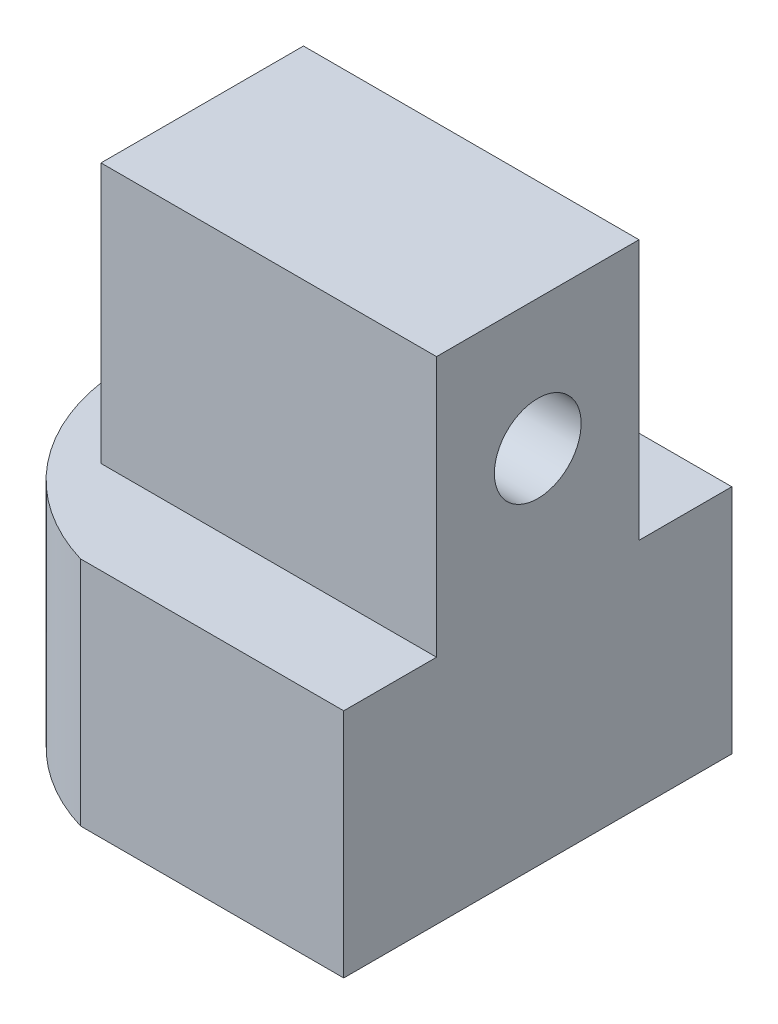
from build123d import *

# Parameters (mm, degrees)
SKETCH1_R           = 7
SKETCH1_R_2         = 4
BOSS_EXTRUDE1_DEPTH = 6
SKETCH2_R           = 7
BOSS_EXTRUDE2_DEPTH = 10
CUT_EXTRUDE1_DEPTH  = 8
SKETCH4_W           = 4.3
SKETCH4_H           = 6.3
CUT_EXTRUDE2_DEPTH  = 6
SKETCH5_OUTSIDE_W   = 21.092
SKETCH5_OUTSIDE_H   = 21.092
CUT_EXTRUDE3_DEPTH  = 8
BOSS_EXTRUDE3_DEPTH = 8
SKETCH9_R           = 7
CUT_EXTRUDE6_DEPTH  = 8
SKETCH10_W          = 9
SKETCH10_H          = 7
BOSS_EXTRUDE5_DEPTH = 9
SKETCH11_W          = 4.3
SKETCH11_H          = 6.3
CUT_EXTRUDE7_DEPTH  = 6
BOSS_EXTRUDE6_DEPTH = 8
SKETCH14_W          = 7
SKETCH14_H          = 9
BOSS_EXTRUDE7_DEPTH = 2.6
SKETCH15_W          = 4
SKETCH15_H          = 5
CUT_EXTRUDE10_DEPTH = 9
SKETCH16_R          = 1.5
CUT_EXTRUDE11_DEPTH = 6.6


with BuildPart() as part:
    # Sketch1 → Boss-Extrude1 (new body)
    with BuildSketch(Plane(origin=(0, 0, 0), x_dir=(1, 0, 0), z_dir=(0, 1, 0))):
        with Locations(Location((0, 0, 0), (0, 0, 270))):  # turned: the seam where the file's is
            Circle(SKETCH1_R)
        with Locations(Location((0, 0, 0), (0, 0, 270))):  # turned: the seam where the file's is
            Circle(SKETCH1_R_2, mode=Mode.SUBTRACT)
    extrude(amount=BOSS_EXTRUDE1_DEPTH)

    # Sketch2 → Boss-Extrude2 (add)
    with BuildSketch(Plane(origin=(0, 6, 0), x_dir=(1, 0, 0), z_dir=(0, 1, 0))):
        with Locations(Location((0, 0, 0), (0, 0, 270))):  # turned: the seam where the file's is
            Circle(SKETCH2_R)
    extrude(amount=BOSS_EXTRUDE2_DEPTH)

    # Sketch3 → Cut-Extrude1 (cut)
    with BuildSketch(Plane(origin=(0, 16, 0), x_dir=(1, 0, 0), z_dir=(0, 1, 0))):
        with BuildLine():
            Line((0, 7), (0, -7))
            ThreePointArc((0, -7), (-7, 0), (0, 7))
        make_face()
    extrude(amount=-CUT_EXTRUDE1_DEPTH, mode=Mode.SUBTRACT)

    # Sketch4 → Cut-Extrude2 (cut)
    with BuildSketch(Plane.ZY):
        with Locations((0, 12.15)):
            Rectangle(SKETCH4_W, SKETCH4_H)
    extrude(amount=-CUT_EXTRUDE2_DEPTH, mode=Mode.SUBTRACT)

    # Sketch5 outside → Cut-Extrude3 (cut)
    with BuildSketch(Plane(origin=(0, 16, 0), x_dir=(1, 0, 0), z_dir=(0, 1, 0))):
        Rectangle(SKETCH5_OUTSIDE_W, SKETCH5_OUTSIDE_H)
        with BuildLine():
            Line((0, 4), (5.744562647, 4))
            ThreePointArc((5.744562647, 4), (7, 0), (5.744562647, -4))
            Line((5.744562647, -4), (0, -4))
            Line((0, -4), (0, 4))
        make_face(mode=Mode.SUBTRACT)
    extrude(amount=-CUT_EXTRUDE3_DEPTH, mode=Mode.SUBTRACT)

    # Sketch7 → Boss-Extrude3 (add)
    with BuildSketch(Plane(origin=(0, 8, 0), x_dir=(1, 0, 0), z_dir=(0, 1, 0))):
        with BuildLine():
            Line((2, 6.708203932), (2, 11.708203932))
            Line((2, 11.708203932), (-2, 11.708203932))
            Line((-2, 11.708203932), (-2, 6.708203932))
            ThreePointArc((-2, 6.708203932), (0, 7), (2, 6.708203932))
        make_face()
        with BuildLine():
            Line((2, -6.708203932), (2, -11.708203932))
            Line((2, -11.708203932), (-2, -11.708203932))
            Line((-2, -11.708203932), (-2, -6.708203932))
            ThreePointArc((-2, -6.708203932), (0, -7), (2, -6.708203932))
        make_face()
    extrude(amount=-BOSS_EXTRUDE3_DEPTH)

    # Sketch9 → Cut-Extrude6 (cut)
    with BuildSketch(Plane(origin=(0, 16, 0), x_dir=(1, 0, 0), z_dir=(0, 1, 0))):
        Circle(SKETCH9_R)
    extrude(amount=-CUT_EXTRUDE6_DEPTH, mode=Mode.SUBTRACT)

    # Sketch10 → Boss-Extrude5 (add)
    with BuildSketch(Plane(origin=(0, 8, 0), x_dir=(1, 0, 0), z_dir=(0, 1, 0))):
        Rectangle(SKETCH10_W, SKETCH10_H)
    extrude(amount=BOSS_EXTRUDE5_DEPTH)

    # Sketch11 → Cut-Extrude7 (cut)
    with BuildSketch(Plane.ZY.offset(4.5)):
        with Locations((0, 12.5)):
            Rectangle(SKETCH11_W, SKETCH11_H)
    extrude(amount=-CUT_EXTRUDE7_DEPTH, mode=Mode.SUBTRACT)

    # Sketch13 → Boss-Extrude6 (add)
    with BuildSketch(Plane(origin=(0, 8, 0), x_dir=(1, 0, 0), z_dir=(0, 1, 0))):
        with BuildLine():
            Line((2, -6.708203932), (7.1, -6.708203932))
            Line((7.1, -6.708203932), (7.1, 6.708203932))
            Line((7.1, 6.708203932), (2, 6.708203932))
            ThreePointArc((2, 6.708203932), (7, 0), (2, -6.708203932))
        make_face()
    extrude(amount=-BOSS_EXTRUDE6_DEPTH)

    # Sketch14 → Boss-Extrude7 (add)
    with BuildSketch(Plane(origin=(4.5, 0, 0), x_dir=(0, 0, -1), z_dir=(1, 0, 0))):
        with Locations((0, 12.5)):
            Rectangle(SKETCH14_W, SKETCH14_H)
    extrude(amount=BOSS_EXTRUDE7_DEPTH)

    # Sketch15 → Cut-Extrude10 (cut, through all)
    with BuildSketch(Plane(origin=(0, 8, 0), x_dir=(1, 0, 0), z_dir=(0, 1, 0))):
        with Locations((0, 9.208203932)):
            Rectangle(SKETCH15_W, SKETCH15_H)
        with Locations((0, -9.208203932)):
            Rectangle(SKETCH15_W, SKETCH15_H)
    extrude(amount=-CUT_EXTRUDE10_DEPTH, mode=Mode.SUBTRACT)

    # Sketch16 → Cut-Extrude11 (cut, through all)
    with BuildSketch(Plane.ZY.offset(-1.5)):
        with Locations((0, 12.5)):
            Circle(SKETCH16_R)
    extrude(amount=-CUT_EXTRUDE11_DEPTH, mode=Mode.SUBTRACT)


solid = part.part
